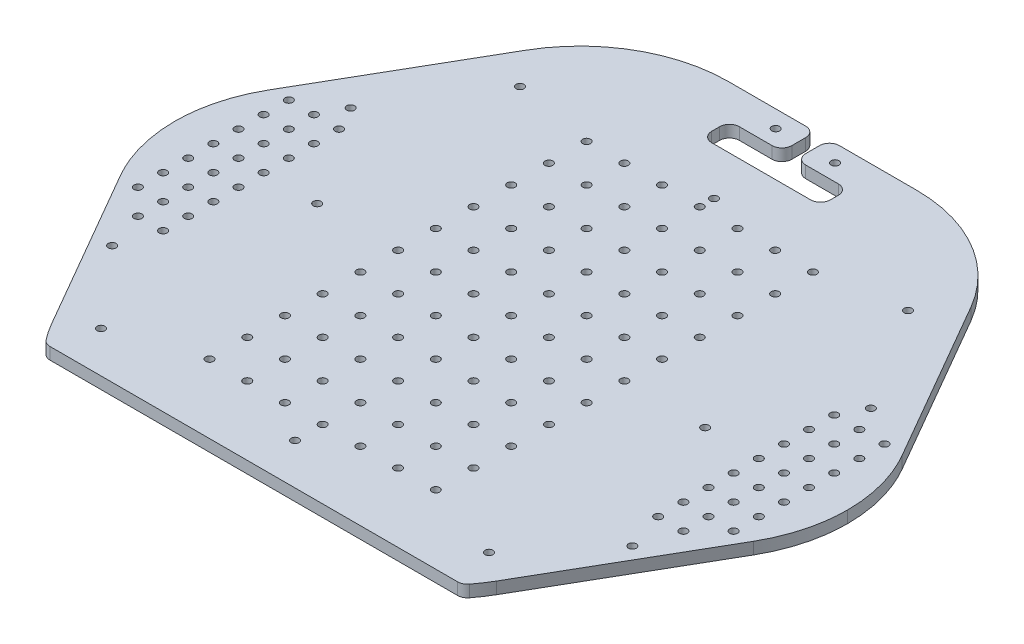
from build123d import *

# Parameters (mm, degrees)
BOSS_EXTRUDE1_DEPTH        = 6
CUT_EXTRUDE1_DEPTH         = 7.0000001
M3_5_CLEARANCE_HOLE1_D     = 3.949564791
M3_5_CLEARANCE_HOLE1_DEPTH = 6.000055
M3_5_CLEARANCE_HOLE2_D     = 3.949564791
M3_5_CLEARANCE_HOLE2_DEPTH = 6.000055
FILLET1_R                  = 5.02065441
FILLET2_R                  = 74.958489821


with BuildPart() as part:
    # Sketch1 → Boss-Extrude1 (new body)
    with BuildSketch(Plane(origin=(0, 6, 0), x_dir=(1, 0, 0), z_dir=(0, 1, 0))):
        with BuildLine():
            Line((112.451900879, -119.772412512), (159.951903815, -37.500000848))
            add(Edge.make_bspline(
                [(159.951903815, -37.500000848), (162.089841538, -33.796778918), (165.842589826, -25.786061926), (169.244511458, -13.089917553), (169.999894602, -4.276058992), (169.999997188, -5.864e-06)],
                knots=[2.617993882, 2.617993882, 2.617993882, 2.617993882, 2.789036145, 2.970550387, 3.141592649, 3.141592649, 3.141592649, 3.141592649], degree=3))
            add(Edge.make_bspline(
                [(169.999997188, -5.864e-06), (169.999894602, 4.276047264), (169.244511458, 13.089905825), (165.842589826, 25.786050198), (162.089841538, 33.79676719), (159.951903815, 37.49998912)],
                knots=[3.141592658, 3.141592658, 3.141592658, 3.141592658, 3.31263492, 3.494149162, 3.665191425, 3.665191425, 3.665191425, 3.665191425], degree=3))
            Line((159.951903815, 37.49998912), (90.801278878, 157.272408343))
            Line((90.801278878, 157.272408343), (-90.8012615, 157.272408343))
            Line((-90.8012615, 157.272408343), (-159.951896595, 37.499994984))
            add(Edge.make_bspline(
                [(-159.951896595, 37.499994984), (-162.089834317, 33.796773054), (-165.842582605, 25.786056062), (-169.244504237, 13.08991169), (-169.999887381, 4.276053128), (-169.999989967, 0)],
                knots=[5.759586536, 5.759586536, 5.759586536, 5.759586536, 5.930628798, 6.11214304, 6.283185303, 6.283185303, 6.283185303, 6.283185303], degree=3))
            add(Edge.make_bspline(
                [(-169.999989967, 0), (-169.999887381, -4.276053128), (-169.244504237, -13.089911689), (-165.842582605, -25.786056062), (-162.089834317, -33.796773054), (-159.951896595, -37.499994984)],
                knots=[6.283185312, 6.283185312, 6.283185312, 6.283185312, 6.454227574, 6.635741816, 6.806784078, 6.806784078, 6.806784078, 6.806784078], degree=3))
            Line((-159.951896595, -37.499994984), (-112.451903815, -119.772412512))
            add(Edge.make_bspline(
                [(-112.451903815, -119.772412512), (-110.697042547, -122.811840435), (-108.72856528, -125.72791615), (-106.565705299, -128.491919084), (-106.17234227, -128.994613005), (-105.778979241, -129.497306926), (-105.385616213, -130.000000848)],
                knots=[0.523598778, 0.523598778, 0.523598778, 0.523598778, 0.663984963, 0.663984963, 0.663984963, 0.689517237, 0.689517237, 0.689517237, 0.689517237], degree=3))
            Line((-105.385616213, -130.000000848), (105.385613276, -130.000000848))
            add(Edge.make_bspline(
                [(105.385613276, -130.000000848), (105.778976305, -129.497306926), (106.172339333, -128.994613005), (106.565702362, -128.491919084), (108.728562343, -125.72791615), (110.69703961, -122.811840435), (112.451900879, -119.772412512)],
                knots=[2.452075416, 2.452075416, 2.452075416, 2.452075416, 2.477607691, 2.477607691, 2.477607691, 2.617993876, 2.617993876, 2.617993876, 2.617993876], degree=3))
        make_face()
    extrude(amount=-BOSS_EXTRUDE1_DEPTH)

    # Sketch2 → Cut-Extrude1 (cut, through all)
    with BuildSketch(Plane.XZ):
        Polygon((3.5, -157.27241336), (3.5, -140.27241336), (30, -140.27241336), (30, -126.27241336), (-30, -126.27241336), (-30, -140.27241336), (-3.5, -140.27241336), (-3.5, -157.27241336), align=None)
    extrude(amount=-CUT_EXTRUDE1_DEPTH, mode=Mode.SUBTRACT)

    # M3.5 Clearance Hole1
    with Locations(Plane(origin=(0, 6, 0), x_dir=(1, 0, 0), z_dir=(0, 1, 0))):
        with Locations((-150.4696, 38.100037129), (-150.4696, 25.400037129), (-150.4696, 12.700037129), (-150.4696, 3.7129e-05), (-150.4696, -12.699962871), (-150.4696, -25.399962871), (-150.4696, -38.099962871), (150.4696, -38.099962871), (150.4696, -25.399962871), (150.4696, -12.699962871), (150.4696, 3.7129e-05), (150.4696, 12.700037129), (150.4696, 25.400037129), (150.4696, 38.100037129)):
            Hole(M3_5_CLEARANCE_HOLE1_D / 2, depth=M3_5_CLEARANCE_HOLE1_DEPTH)

    # M3.5 Clearance Hole2
    with Locations(Plane(origin=(0, 0, 0), x_dir=(-1, 0, 0), z_dir=(0, -1, 0))):
        with Locations((98, -109.219962871), (-98, 102.438237129), (98, 102.438237129), (0, 102.438237129), (0, -109.219962871), (0, 3.7129e-05), (-19.05, 3.7129e-05), (-19.05, 19.050037129), (0, 19.050037129), (19.05, 19.050037129), (19.05, 3.7129e-05), (19.05, -19.049962871), (0, -19.049962871), (-19.05, -19.049962871), (-38.1, -19.049962871), (-38.1, 3.7129e-05), (-38.1, 19.050037129), (-38.1, 38.100037129), (-19.05, 38.100037129), (0, 38.100037129), (19.05, 38.100037129), (38.1, 38.100037129), (38.1, 19.050037129), (38.1, 3.7129e-05), (38.1, -19.049962871), (38.1, -38.099962871), (19.05, -38.099962871), (0, -38.099962871), (-19.05, -38.099962871), (-38.1, -38.099962871), (-57.15, -38.099962871), (-57.15, -19.049962871), (-57.15, 3.7129e-05), (-57.15, 19.050037129), (-57.15, 38.100037129), (-57.15, 57.150037129), (-38.1, 57.150037129), (-19.05, 57.150037129), (0, 57.150037129), (19.05, 57.150037129), (38.1, 57.150037129), (57.15, 57.150037129), (57.15, 38.100037129), (57.15, 19.050037129), (57.15, 3.7129e-05), (57.15, -19.049962871), (57.15, -38.099962871), (57.15, -57.149962871), (38.1, -57.149962871), (19.05, -57.149962871), (0, -57.149962871), (-19.05, -57.149962871), (-38.1, -57.149962871), (-57.15, -57.149962871), (-57.15, 76.200037129), (-38.1, 76.200037129), (-19.05, 76.200037129), (0, 76.200037129), (19.05, 76.200037129), (38.1, 76.200037129), (57.15, 76.200037129), (57.15, -76.199962871), (38.1, -76.199962871), (19.05, -76.199962871), (0, -76.199962871), (-19.05, -76.199962871), (-38.1, -76.199962871), (-57.15, -76.199962871), (-57.15, 95.250037129), (-38.1, 95.250037129), (-19.05, 95.250037129), (0, 95.250037129), (19.05, 95.250037129), (38.1, 95.250037129), (57.15, 95.250037129), (57.15, -95.249962871), (38.1, -95.249962871), (19.05, -95.249962871), (0, -95.249962871), (-19.05, -95.249962871), (-38.1, -95.249962871), (-57.15, -95.249962871), (-97.9932, -3.7129e-05), (-125.0696, -3.7129e-05), (-137.7696, -3.7129e-05), (-125.0696, -12.700037129), (-125.0696, -25.400037129), (-125.0696, -38.100037129), (-137.7696, -38.100037129), (-137.7696, -25.400037129), (-137.7696, -12.700037129), (-125.0696, 12.699962871), (-125.0696, 25.399962871), (-125.0696, 38.099962871), (-137.7696, 38.099962871), (-137.7696, 25.399962871), (-137.7696, 12.699962871), (97.9932, -3.7129e-05), (125.0696, -3.7129e-05), (137.7696, -3.7129e-05), (125.0696, -12.700037129), (125.0696, -25.400037129), (125.0696, -38.100037129), (137.7696, -38.100037129), (137.7696, -25.400037129), (137.7696, -12.700037129), (125.0696, 12.699962871), (125.0696, 25.399962871), (125.0696, 38.099962871), (137.7696, 38.099962871), (137.7696, 25.399962871), (137.7696, 12.699962871), (-137.7696, -50.800037129), (-125.0696, -50.800037129), (137.7696, -50.800037129), (125.0696, -50.800037129), (-98, -109.219962871), (131.4, 50.300037129), (-131.4, 50.300037129), (131.4, -70.199962871), (-131.4, -70.199962871), (15, 148.600037129), (-15, 148.600037129)):
            Hole(M3_5_CLEARANCE_HOLE2_D / 2, depth=M3_5_CLEARANCE_HOLE2_DEPTH)

    # Fillet1
    fillet1_edges = [part.edges().sort_by_distance(p)[0] for p in [
        (-105.385616213, 3, 130.000000848),
        (3.5, 3, -140.27241336),
        (-3.5, 3, -157.272408343),
        (-30, 3, -126.27241336),
        (3.5, 3, -157.272408343),
        (-30, 3, -140.27241336),
        (-3.5, 3, -140.27241336),
        (30, 3, -140.27241336),
        (105.385613276, 3, 130.000000848),
        (30, 3, -126.27241336),
    ]]
    fillet(fillet1_edges, radius=FILLET1_R)

    # Fillet2
    fillet2_edges = [part.edges().sort_by_distance(p)[0] for p in [
        (90.801278878, 3, -157.272408343),
        (-90.8012615, 3, -157.272408343),
    ]]
    fillet(fillet2_edges, radius=FILLET2_R)


solid = part.part
